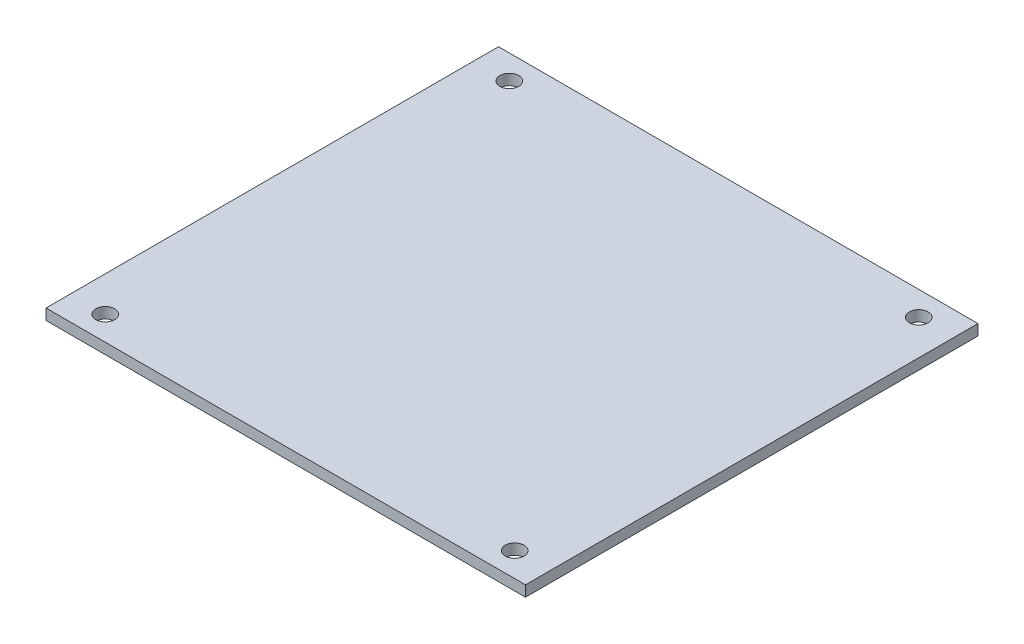
from build123d import *

# Parameters (mm, degrees)
SKETCH1_W           = 89
SKETCH1_H           = 84
BOSS_EXTRUDE1_DEPTH = 2
SKETCH2_R           = 1.75
CUT_EXTRUDE1_DEPTH  = 10


with BuildPart() as part:
    # Sketch1 → Boss-Extrude1 (new body)
    with BuildSketch(Plane(origin=(0, 0, 0), x_dir=(1, 0, 0), z_dir=(0, 1, 0))):
        Rectangle(SKETCH1_W, SKETCH1_H)
    extrude(amount=BOSS_EXTRUDE1_DEPTH)

    # Sketch2 → Cut-Extrude1 (cut)
    with BuildSketch(Plane.XZ):
        with Locations((-38, 37.5)):
            Circle(SKETCH2_R)
        with Locations((-38, -37.5)):
            Circle(SKETCH2_R)
        with Locations((38, -37.5)):
            Circle(SKETCH2_R)
        with Locations((38, 37.5)):
            Circle(SKETCH2_R)
    extrude(amount=-CUT_EXTRUDE1_DEPTH, mode=Mode.SUBTRACT)


solid = part.part
